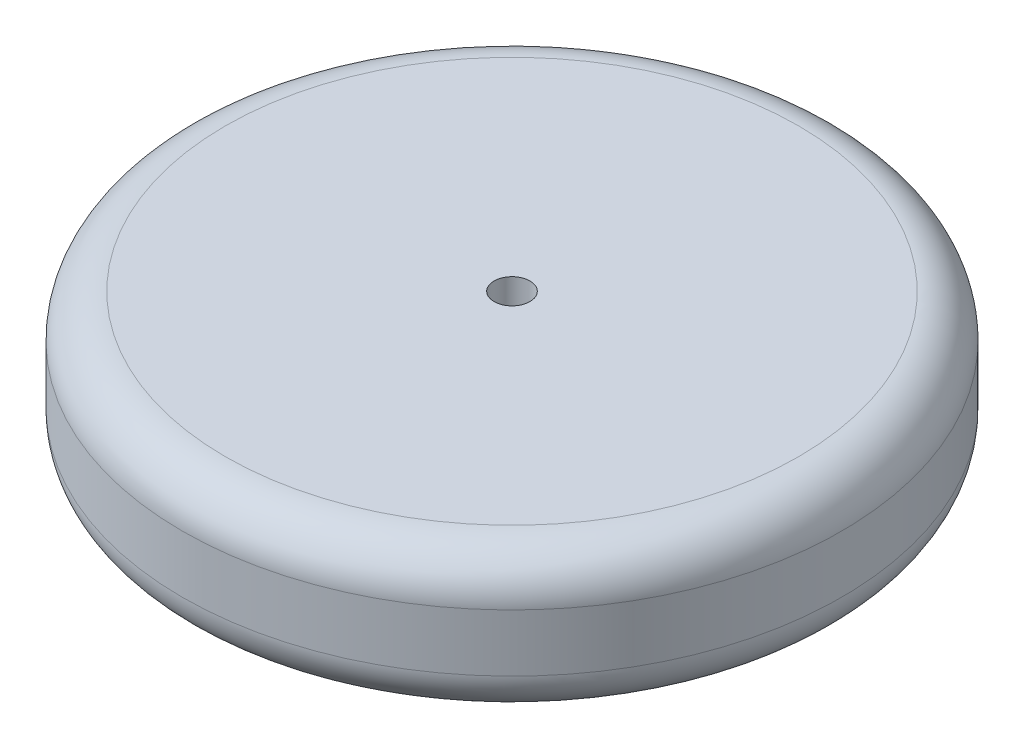
from build123d import *

# Parameters (mm, degrees)
SKETCH1_R           = 292.1
BOSS_EXTRUDE1_DEPTH = 127
FILLET1_R           = 38.1
SKETCH2_R           = 15.875
CUT_EXTRUDE1_DEPTH  = 128


with BuildPart() as part:
    # Sketch1 → Boss-Extrude1 (new body)
    with BuildSketch(Plane(origin=(0, 0, 0), x_dir=(1, 0, 0), z_dir=(0, 1, 0))):
        Circle(SKETCH1_R)
    extrude(amount=BOSS_EXTRUDE1_DEPTH)

    # Fillet1
    fillet1_edges = [part.edges().sort_by_distance(p)[0] for p in [
        (-292.1, 0, 0),
        (-292.1, 127, 0),
    ]]
    fillet(fillet1_edges, radius=FILLET1_R)

    # Sketch2 → Cut-Extrude1 (cut, through all)
    with BuildSketch(Plane(origin=(0, 127, 0), x_dir=(1, 0, 0), z_dir=(0, 1, 0))):
        Circle(SKETCH2_R)
    extrude(amount=-CUT_EXTRUDE1_DEPTH, mode=Mode.SUBTRACT)


solid = part.part
